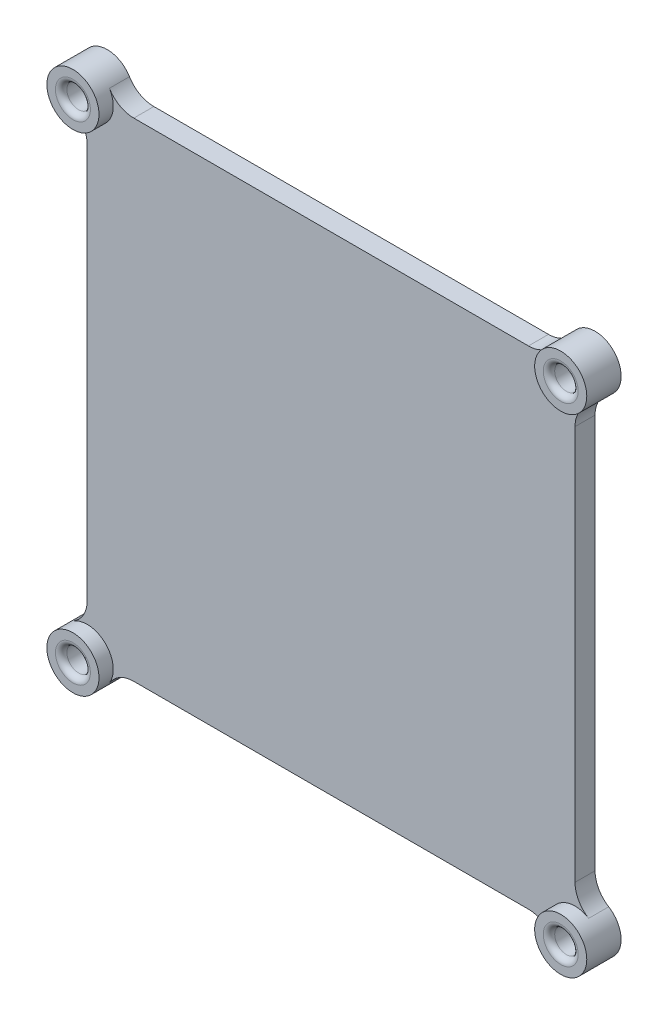
from build123d import *

# Parameters (mm, degrees)
SKETCH1_R           = 2.05
BOSS_EXTRUDE1_DEPTH = 3.5
FILLET1_R           = 5
SKETCH2_R           = 4.55
BOSS_EXTRUDE2_DEPTH = 1
SKETCH3_R           = 4.55
SKETCH3_R_2         = 2.05
BOSS_EXTRUDE3_DEPTH = 2.5
FILLET2_R           = 1


with BuildPart() as part:
    # Sketch1 → Boss-Extrude1 (new body)
    with BuildSketch(Plane.XY):
        with BuildLine():
            ThreePointArc((82.7, -2.05), (85.917335854, 5.717335854), (78.15, 2.5))
            Line((78.15, 2.5), (2.05, 2.5))
            ThreePointArc((2.05, 2.5), (-5.717335854, 5.717335854), (-2.5, -2.05))
            Line((-2.5, -2.05), (-2.5, -78.15))
            ThreePointArc((-2.5, -78.15), (-5.717335854, -85.917335854), (2.05, -82.7))
            Line((2.05, -82.7), (78.15, -82.7))
            ThreePointArc((78.15, -82.7), (85.917335854, -85.917335854), (82.7, -78.15))
            Line((82.7, -78.15), (82.7, -2.05))
        make_face()
        with Locations((82.7, -82.7)):
            Circle(SKETCH1_R, mode=Mode.SUBTRACT)
        with Locations((-2.5, -82.7)):
            Circle(SKETCH1_R, mode=Mode.SUBTRACT)
        with Locations((82.7, 2.5)):
            Circle(SKETCH1_R, mode=Mode.SUBTRACT)
        with Locations((-2.5, 2.5)):
            Circle(SKETCH1_R, mode=Mode.SUBTRACT)
    extrude(amount=BOSS_EXTRUDE1_DEPTH)

    # Fillet1
    fillet1_edges = [part.edges().sort_by_distance(p)[0] for p in [
        (2.05, 2.5, 1.75),
        (78.15, 2.5, 1.75),
        (82.7, -2.05, 1.75),
        (82.7, -78.15, 1.75),
        (78.15, -82.7, 1.75),
        (2.05, -82.7, 1.75),
        (-2.5, -78.15, 1.75),
        (-2.5, -2.05, 1.75),
    ]]
    fillet(fillet1_edges, radius=FILLET1_R)

    # Sketch2 → Boss-Extrude2 (add)
    with BuildSketch(Plane(origin=(0, 0, 0), x_dir=(-1, 0, 0), z_dir=(0, 0, -1))):
        with Locations((-82.7, 2.5)):
            Circle(SKETCH2_R)
        with Locations((2.5, 2.5)):
            Circle(SKETCH2_R)
        with Locations((2.5, -82.7)):
            Circle(SKETCH2_R)
        with Locations((-82.7, -82.7)):
            Circle(SKETCH2_R)
    extrude(amount=-BOSS_EXTRUDE2_DEPTH)

    # Sketch3 → Boss-Extrude3 (add)
    with BuildSketch(Plane.XY.offset(3.5)):
        with Locations((-2.5, 2.5)):
            Circle(SKETCH3_R)
        with Locations((-2.5, 2.5)):
            Circle(SKETCH3_R_2, mode=Mode.SUBTRACT)
        with Locations((82.7, 2.5)):
            Circle(SKETCH3_R)
        with Locations((82.7, 2.5)):
            Circle(SKETCH3_R_2, mode=Mode.SUBTRACT)
        with Locations((82.7, -82.7)):
            Circle(SKETCH3_R)
        with Locations((82.7, -82.7)):
            Circle(SKETCH3_R_2, mode=Mode.SUBTRACT)
        with Locations((-2.5, -82.7)):
            Circle(SKETCH3_R)
        with Locations((-2.5, -82.7)):
            Circle(SKETCH3_R_2, mode=Mode.SUBTRACT)
    extrude(amount=BOSS_EXTRUDE3_DEPTH)

    # Fillet2
    fillet2_edges = [part.edges().sort_by_distance(p)[0] for p in [
        (-4.55, 2.5, 6),
        (80.65, 2.5, 6),
        (80.65, -82.7, 6),
        (-4.55, -82.7, 6),
    ]]
    fillet(fillet2_edges, radius=FILLET2_R)


solid = part.part
